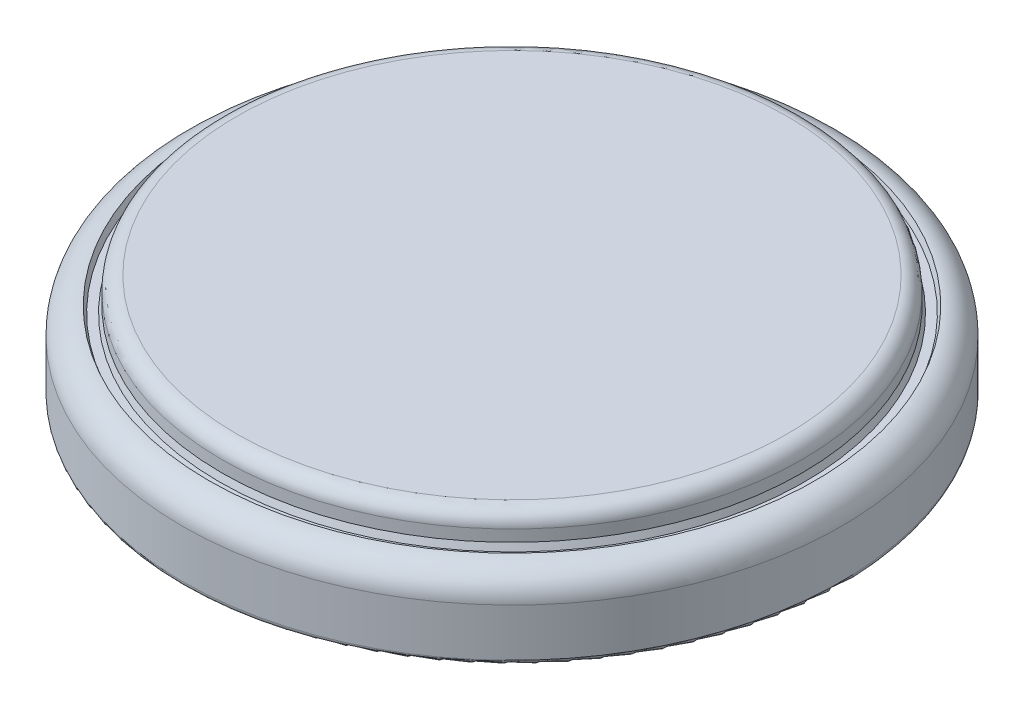
from build123d import *

# Parameters (mm, degrees)
SKETCH1_R          = 10
EXTRUDE1_DEPTH     = 2.4
SKETCH2_R          = 8.8
EXTRUDE2_DEPTH     = 3.2
FILLET1_R          = 0.8
FILLET2_R          = 0.15
FILLET3_R          = 0.45
SKETCH3_R          = 9.2
SKETCH3_R_2        = 8.8
CUT_EXTRUDE2_DEPTH = 0.2
CUT_EXTRUDE2_TAPER = 20


with BuildPart() as part:
    # Sketch1 → Extrude1 (new body)
    with BuildSketch(Plane(origin=(0, 0, 0), x_dir=(1, 0, 0), z_dir=(0, 1, 0))):
        Circle(SKETCH1_R)
    extrude(amount=EXTRUDE1_DEPTH)

    # Sketch2 → Extrude2 (add)
    with BuildSketch(Plane(origin=(0, 0, 0), x_dir=(1, 0, 0), z_dir=(0, 1, 0))):
        Circle(SKETCH2_R)
    extrude(amount=EXTRUDE2_DEPTH)

    # Fillet1
    fillet1_edges = [part.edges().sort_by_distance(p)[0] for p in [
        (-10, 2.4, 0),
    ]]
    fillet(fillet1_edges, radius=FILLET1_R)

    # Fillet2
    fillet2_edges = [part.edges().sort_by_distance(p)[0] for p in [
        (-10, 0, 0),
    ]]
    fillet(fillet2_edges, radius=FILLET2_R)

    # Fillet3
    fillet3_edges = [part.edges().sort_by_distance(p)[0] for p in [
        (-8.8, 3.2, 0),
    ]]
    fillet(fillet3_edges, radius=FILLET3_R)

    # Sketch3 → Cut-Extrude2 (cut)
    with BuildSketch(Plane(origin=(0, 2.4, 0), x_dir=(-1, 0, 0), z_dir=(0, 1, 0))):
        Circle(SKETCH3_R)
        Circle(SKETCH3_R_2, mode=Mode.SUBTRACT)
    extrude(amount=-CUT_EXTRUDE2_DEPTH, taper=CUT_EXTRUDE2_TAPER, mode=Mode.SUBTRACT)


solid = part.part
